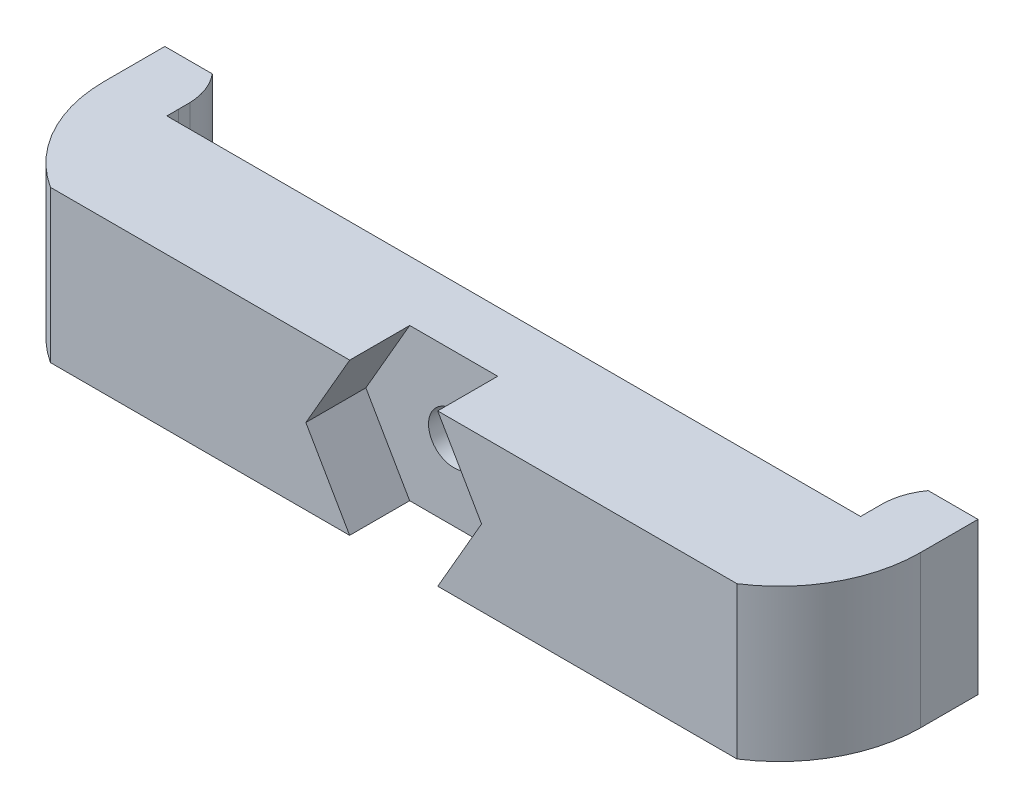
from build123d import *

# Parameters (mm, degrees)
EXTRUDE_1_DEPTH     = 12.65
CUT_EXTRUDE_1_DEPTH = 5
SKETCH_3_R          = 4.75
CUT_EXTRUDE_2_DEPTH = 3
SKETCH_6_R          = 2.1
CUT_EXTRUDE_5_DEPTH = 10
FILLET_3_R          = 5
FILLET_4_R          = 5
FILLET_6_R          = 1
FILLET_7_R          = 1
CUT_EXTRUDE_6_DEPTH = 15


with BuildPart() as part:
    # 草图1 → 凸台-拉伸1 (new body)
    with BuildSketch(Plane(origin=(0, 0, 0), x_dir=(1, 0, 0), z_dir=(0, 1, 0))):
        with BuildLine():
            Line((-28.6, 0), (28.6, 0))
            ThreePointArc((28.6, 0), (32.562096374, 4.25705164), (34, 9.892043165))
            Line((34, 9.892043165), (34, 17.266133288))
            Line((34, 17.266133288), (28.9, 15))
            Line((28.9, 15), (28.9, 10))
            Line((28.9, 10), (-28.9, 10))
            Line((-28.9, 10), (-28.9, 15))
            Line((-28.9, 15), (-34, 17.266133288))
            Line((-34, 17.266133288), (-34, 9.892043165))
            ThreePointArc((-34, 9.892043165), (-32.562096374, 4.25705164), (-28.6, 0))
        make_face()
    extrude(amount=EXTRUDE_1_DEPTH)

    # 草图2 → 切除-拉伸1 (cut)
    with BuildSketch(Plane.XY):
        Polygon((-7.32, 6.32), (-3.66, -0.019305956), (3.66, -0.019305956), (7.32, 6.32), (3.66, 12.659305956), (-3.66, 12.659305956), align=None)
    extrude(amount=-CUT_EXTRUDE_1_DEPTH, mode=Mode.SUBTRACT)

    # 草图3 → 切除-拉伸2 (cut)
    with BuildSketch(Plane(origin=(0, 0, -10), x_dir=(-1, 0, 0), z_dir=(0, 0, -1))):
        with Locations((0, 6.32)):
            Circle(SKETCH_3_R)
    extrude(amount=-CUT_EXTRUDE_2_DEPTH, mode=Mode.SUBTRACT)

    # 草图6 → 切除-拉伸5 (cut)
    with BuildSketch(Plane.XY.offset(-5)):
        with Locations((0, 6.32)):
            Circle(SKETCH_6_R)
    extrude(amount=-CUT_EXTRUDE_5_DEPTH, mode=Mode.SUBTRACT)

    # 圆角3
    fillet_3_edges = [part.edges().sort_by_distance(p)[0] for p in [
        (-28.9, 6.325, -15),
    ]]
    fillet(fillet_3_edges, radius=FILLET_3_R)

    # 圆角4
    fillet_4_edges = [part.edges().sort_by_distance(p)[0] for p in [
        (28.9, 6.325, -15),
    ]]
    fillet(fillet_4_edges, radius=FILLET_4_R)

    # 圆角6
    fillet_6_edges = [part.edges().sort_by_distance(p)[0] for p in [
        (34, 6.325, -17.266133288),
    ]]
    fillet(fillet_6_edges, radius=FILLET_6_R)

    # 圆角7
    fillet_7_edges = [part.edges().sort_by_distance(p)[0] for p in [
        (-34, 6.325, -17.266133288),
    ]]
    fillet(fillet_7_edges, radius=FILLET_7_R)

    # 草图7 → 切除-拉伸6 (cut)
    with BuildSketch(Plane.XZ):
        Polygon((28.903354644, -10.942236709), (27.407544443, -14.683649227), (28.903354644, -17.343343862), (36.500549605, -19.187562633), (35.643870018, -14.683649227), (31.998035106, -14.683649227), (28.903354644, -14.683649227), align=None)
        Polygon((-28.903354644, -10.942236709), (-27.711217355, -14.930549055), (-28.903354644, -15.756236567), (-29.008862033, -15.781540844), (-34.951049449, -20.851021688), (-36.720724333, -14.930549055), (-32.176496035, -14.930549055), (-28.903354644, -14.930549055), align=None)
    extrude(amount=-CUT_EXTRUDE_6_DEPTH, mode=Mode.SUBTRACT)


solid = part.part
